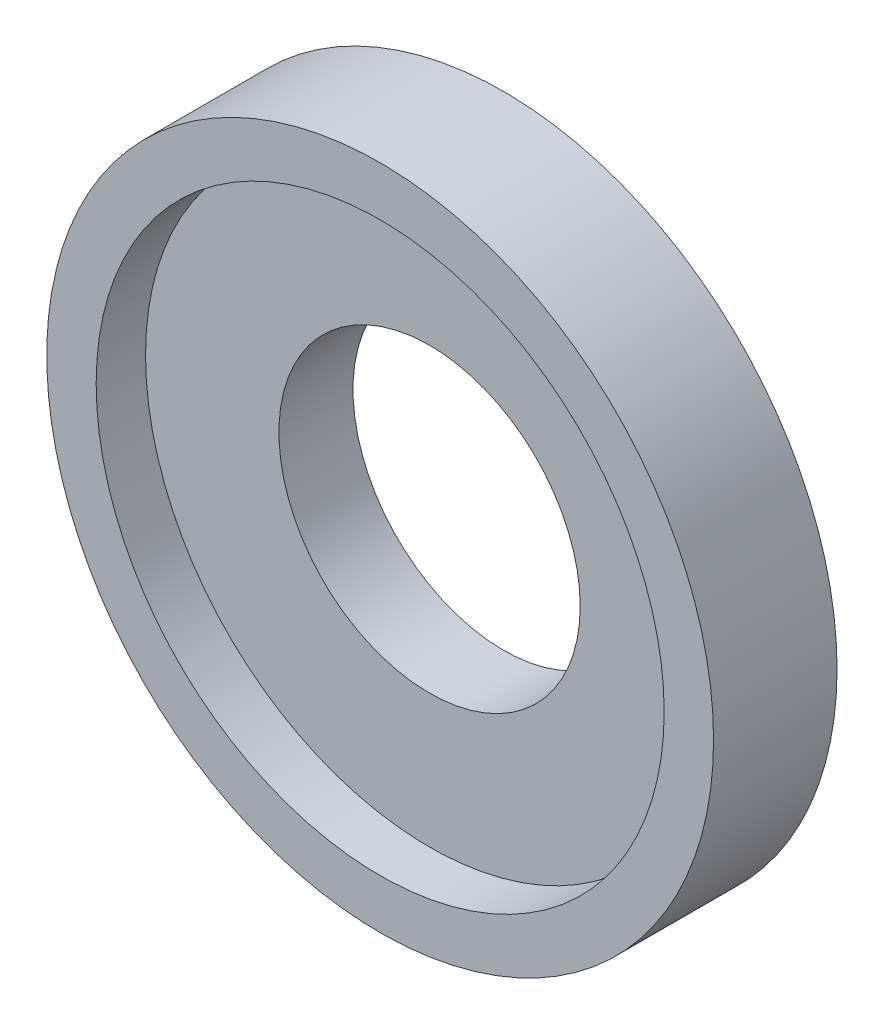
from build123d import *

# Parameters (mm, degrees)
SKETCH_1_R          = 6.75
EXTRUDE_1_DEPTH     = 2.5
SKETCH_2_R          = 3.05
CUT_EXTRUDE_1_DEPTH = 3.5
SKETCH_3_R          = 5.75
CUT_EXTRUDE_2_DEPTH = 1


with BuildPart() as part:
    # 草图1 → 凸台-拉伸1 (new body)
    with BuildSketch(Plane.XY):
        Circle(SKETCH_1_R)
    extrude(amount=EXTRUDE_1_DEPTH)

    # 草图2 → 切除-拉伸1 (cut, through all)
    with BuildSketch(Plane.XY.offset(2.5)):
        Circle(SKETCH_2_R)
    extrude(amount=-CUT_EXTRUDE_1_DEPTH, mode=Mode.SUBTRACT)

    # 草图3 → 切除-拉伸2 (cut)
    with BuildSketch(Plane.XY.offset(2.5)):
        Circle(SKETCH_3_R)
    extrude(amount=-CUT_EXTRUDE_2_DEPTH, mode=Mode.SUBTRACT)


solid = part.part
